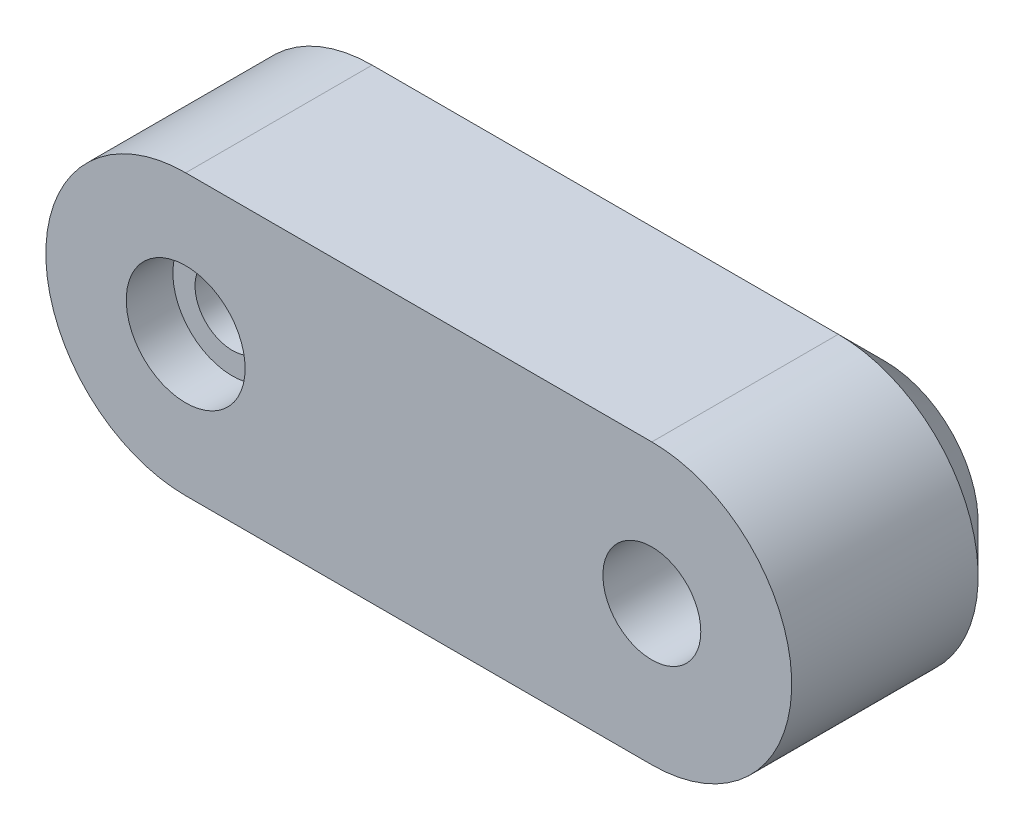
from build123d import *

# Parameters (mm, degrees)
EXTRUDE_1_DEPTH     = 10
CHAMFER_1_SIZE      = 2
CUT_EXTRUDE_1_DEPTH = 4


with BuildPart() as part:
    # 草图1 → 凸台-拉伸1 (new body)
    with BuildSketch(Plane.XY):
        with BuildLine():
            Line((0, 6), (20, 6))
            ThreePointArc((20, 6), (26, 0), (20, -6))
            Line((20, -6), (0, -6))
            ThreePointArc((0, -6), (-6, 0), (0, 6))
        make_face()
    extrude(amount=EXTRUDE_1_DEPTH)

    # 草图2 → 切除-旋转1 (revolve, cut)
    with BuildSketch(Plane(origin=(0, 0, 0), x_dir=(1, 0, 0), z_dir=(0, 1, 0))):
        Polygon((0, 0), (-2.55, 0), (-2.55, -5), (-1.6, -5), (-1.6, -8), (-2.55, -8), (-2.55, -10), (0, -10), align=None)
    revolve(axis=Axis((0, 0, 10), (0, 0, -1)), mode=Mode.SUBTRACT)

    # 草图3 → 切除-旋转2 (revolve, cut)
    with BuildSketch(Plane(origin=(0, 0, 0), x_dir=(1, 0, 0), z_dir=(0, 1, 0))):
        Polygon((20, 0), (17.42, 0), (17.42, -5), (17.9, -5), (17.9, -10), (20, -10), align=None)
    revolve(axis=Axis((20, 0, 10), (0, 0, -1)), mode=Mode.SUBTRACT)

    # 倒角1
    chamfer_1_edges = [part.edges().sort_by_distance(p)[0] for p in [
        (10, 6, 0),
        (26, 0, 0),
        (10, -6, 0),
        (-6, 0, 0),
    ]]
    chamfer(chamfer_1_edges, length=CHAMFER_1_SIZE)

    # 草图4 → 切除-拉伸1 (cut)
    with BuildSketch(Plane(origin=(0, 0, 0), x_dir=(-1, 0, 0), z_dir=(0, 0, -1))):
        Polygon((-23.348631561, 0), (-21.674315781, -2.9), (-18.325684219, -2.9), (-16.651368439, 0), (-18.325684219, 2.9), (-21.674315781, 2.9), align=None)
    extrude(amount=-CUT_EXTRUDE_1_DEPTH, mode=Mode.SUBTRACT)


solid = part.part
